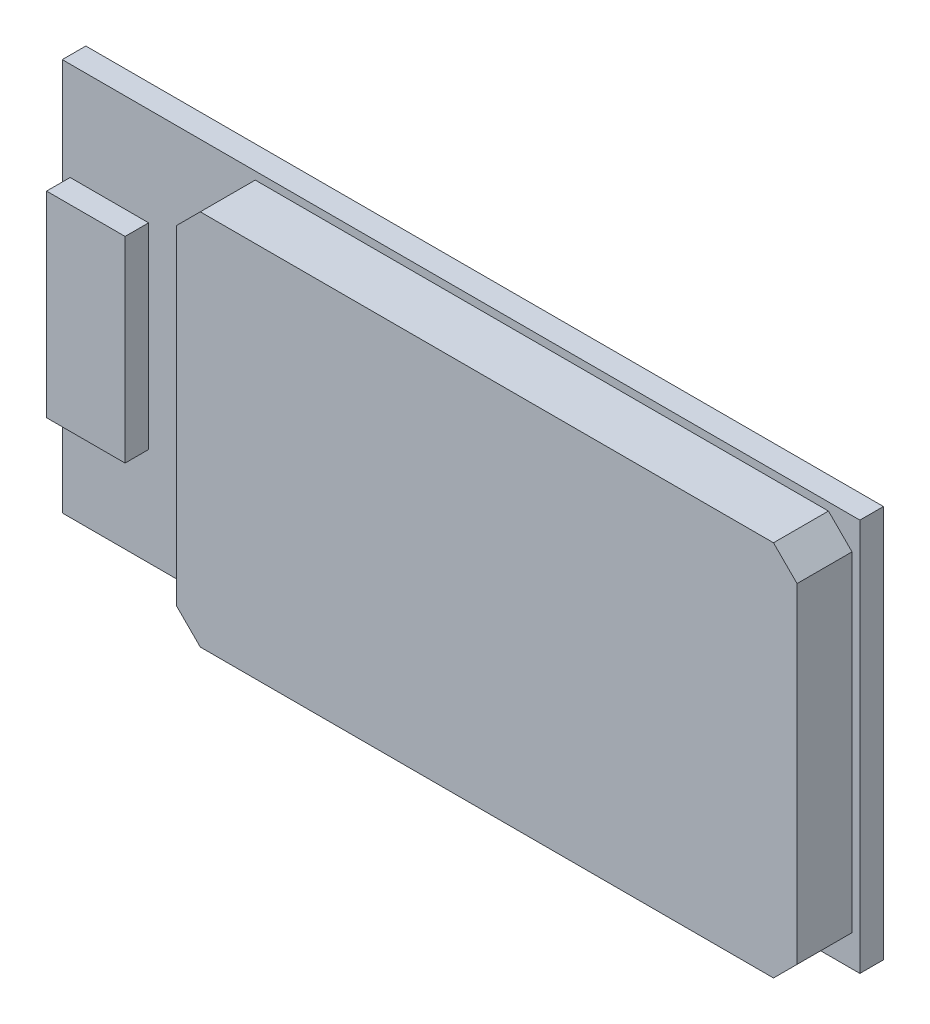
from build123d import *

# Parameters (mm, degrees)
SKETCH1_W           = 25.8
SKETCH1_H           = 12.7
BOSS_EXTRUDE1_DEPTH = 0.762
SKETCH2_W           = 20.066
SKETCH2_H           = 12.192
BOSS_EXTRUDE2_DEPTH = 1.778
CHAMFER1_SIZE       = 0.762
SKETCH3_W           = 2.54
SKETCH3_H           = 6.35
BOSS_EXTRUDE3_DEPTH = 0.762


with BuildPart() as part:
    # Sketch1 → Boss-Extrude1 (new body)
    with BuildSketch(Plane.XY):
        with Locations((12.9, 6.35)):
            Rectangle(SKETCH1_W, SKETCH1_H)
    extrude(amount=BOSS_EXTRUDE1_DEPTH)

    # Sketch2 → Boss-Extrude2 (add)
    with BuildSketch(Plane.XY.offset(0.762)):
        with Locations((15.513, 6.35)):
            Rectangle(SKETCH2_W, SKETCH2_H)
    extrude(amount=BOSS_EXTRUDE2_DEPTH)

    # Chamfer1
    chamfer1_edges = [part.edges().sort_by_distance(p)[0] for p in [
        (5.48, 12.446, 1.651),
        (5.48, 0.254, 1.651),
        (25.546, 0.254, 1.651),
        (25.546, 12.446, 1.651),
    ]]
    chamfer(chamfer1_edges, length=CHAMFER1_SIZE)

    # Sketch3 → Boss-Extrude3 (add)
    with BuildSketch(Plane.XY.offset(0.762)):
        with Locations((1.524, 6.35)):
            Rectangle(SKETCH3_W, SKETCH3_H)
    extrude(amount=BOSS_EXTRUDE3_DEPTH)


solid = part.part
